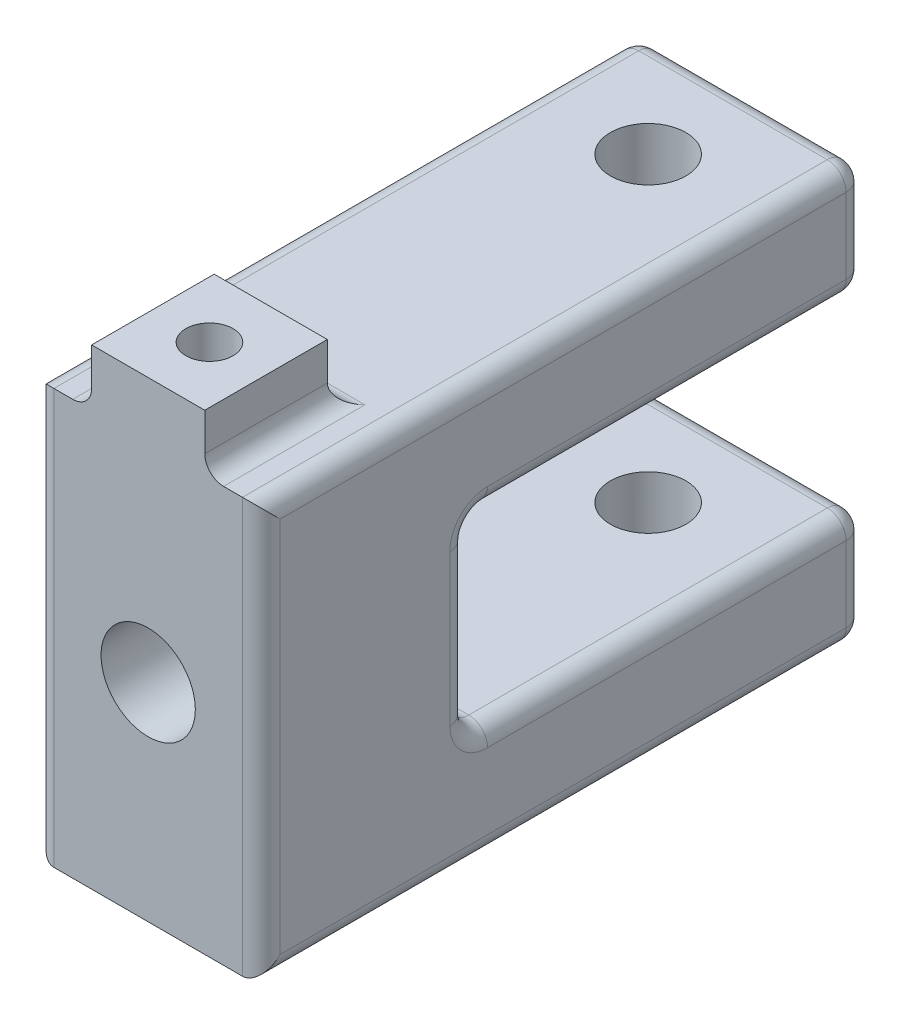
from build123d import *

# Parameters (mm, degrees)
BOSS_EXTRUDE2_DEPTH      = 12
BOSS_EXTRUDE2_DEPTH_BACK = 12
BOSS_EXTRUDE3_DEPTH      = 6
BOSS_EXTRUDE3_DEPTH_BACK = 6
SKETCH1_4_W              = 13
SKETCH1_4_H              = 6
FILLET1_R                = 2
SKETCH2_R                = 2.5
CUT_EXTRUDE1_DEPTH       = 18
CUT_EXTRUDE2_DEPTH       = 71.005908312
CUT_EXTRUDE2_DEPTH_BACK  = 71.005908312
SKETCH4_R                = 4
SKETCH5_R                = 5
CUT_EXTRUDE3_DEPTH       = 35


with BuildPart() as part:
    # Sketch1 → Boss-Extrude2 (new, two sides: drawn at the far end of the back side and taken through both)
    with BuildSketch(Plane(origin=(0, 0, 0), x_dir=(0, 0, -1), z_dir=(1, 0, 0)).offset(-BOSS_EXTRUDE2_DEPTH_BACK)):
        Polygon((10.922768667, 10), (10.922768667, 22), (-40.111460143, 22), (-53.111460143, 22), (-53.111460143, -22), (10.922768667, -22), (10.922768667, -10), (-31.111460143, -10), (-31.111460143, 10), align=None)
    extrude(amount=BOSS_EXTRUDE2_DEPTH + BOSS_EXTRUDE2_DEPTH_BACK)

    # Sketch1_4 → Boss-Extrude3 (add, two sides: drawn at the far end of the back side and taken through both)
    with BuildSketch(Plane(origin=(0, 0, 0), x_dir=(0, 0, -1), z_dir=(1, 0, 0)).offset(-BOSS_EXTRUDE3_DEPTH_BACK)):
        with Locations((-46.611460143, 25)):
            Rectangle(SKETCH1_4_W, SKETCH1_4_H)
    extrude(amount=BOSS_EXTRUDE3_DEPTH + BOSS_EXTRUDE3_DEPTH_BACK)

    # Fillet1
    fillet1_edges = [part.edges().sort_by_distance(p)[0] for p in [
        (12, -22, 21.094345738),
        (12, 0, 53.111460143),
        (12, 22, 21.094345738),
        (0, -22, -10.922768667),
        (0, -10, -10.922768667),
        (12, -16, -10.922768667),
        (12, -10, 10.094345738),
        (12, 10, 10.094345738),
        (12, 0, 31.111460143),
        (6, 22, 46.611460143),
        (0, 22, 40.111460143),
        (-6, 22, 46.611460143),
        (-12, 0, 53.111460143),
        (-12, -22, 21.094345738),
        (0, 10, 31.111460143),
        (0, -10, 31.111460143),
        (-12, -16, -10.922768667),
        (-12, 0, 31.111460143),
        (-12, -10, 10.094345738),
        (-12, 10, 10.094345738),
        (-12, 16, -10.922768667),
        (-12, 22, 21.094345738),
        (12, 16, -10.922768667),
        (0, 10, -10.922768667),
        (0, 22, -10.922768667),
    ]]
    fillet(fillet1_edges, radius=FILLET1_R)

    # Sketch2 → Cut-Extrude1 (cut)
    with BuildSketch(Plane(origin=(0, 28, 0), x_dir=(1, 0, 0), z_dir=(0, 1, 0))):
        with Locations((0, -46.611460143)):
            Circle(SKETCH2_R)
    extrude(amount=-CUT_EXTRUDE1_DEPTH, mode=Mode.SUBTRACT)

    # Sketch4 → Cut-Extrude2 (cut, two sides: drawn at the far end of the back side and taken through both)
    with BuildSketch(Plane(origin=(0, 22, 0), x_dir=(1, 0, 0), z_dir=(0, 1, 0)).offset(-CUT_EXTRUDE2_DEPTH_BACK)):
        with Locations((0, -0.077231333)):
            Circle(SKETCH4_R)
    extrude(amount=CUT_EXTRUDE2_DEPTH + CUT_EXTRUDE2_DEPTH_BACK, mode=Mode.SUBTRACT)

    # Sketch5 → Cut-Extrude3 (cut)
    with BuildSketch(Plane.XY.offset(53.111460143)):
        Circle(SKETCH5_R)
    extrude(amount=-CUT_EXTRUDE3_DEPTH, mode=Mode.SUBTRACT)


solid = part.part
